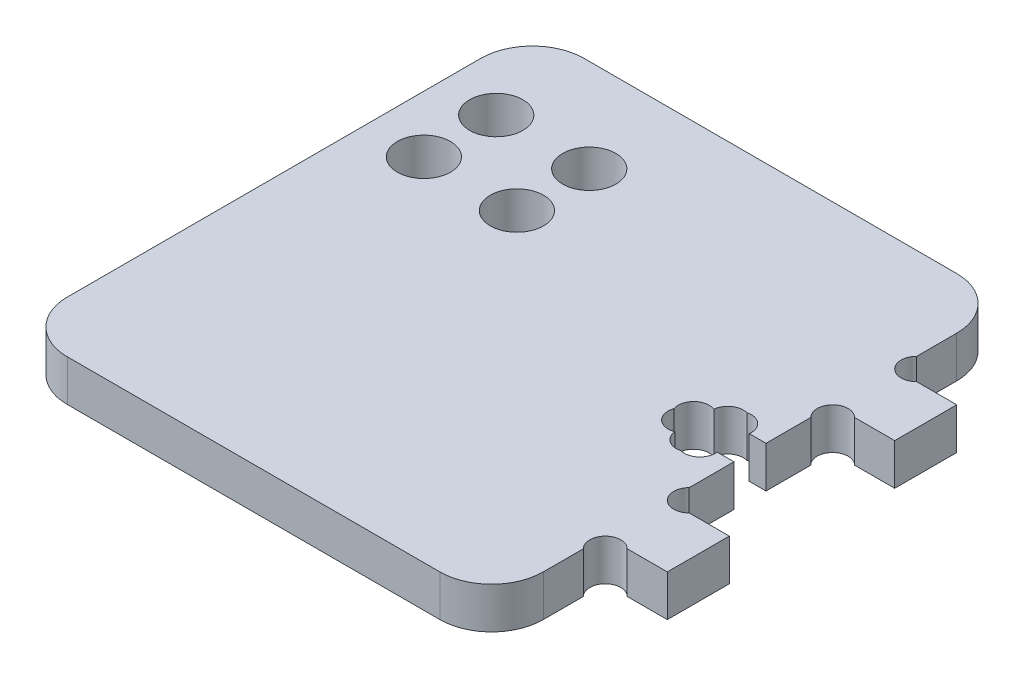
from build123d import *

# Parameters (mm, degrees)
SALIENTE_EXTRUIR1_DEPTH = 4
CORTAR_EXTRUIR4_DEPTH   = 5
CROQUIS10_R             = 1.5
CORTAR_EXTRUIR5_DEPTH   = 5
CROQUIS12_R             = 2.575
CORTAR_EXTRUIR6_DEPTH   = 5


with BuildPart() as part:
    # Croquis1 → Saliente-Extruir1 (new body)
    with BuildSketch(Plane(origin=(0, 0, 0), x_dir=(1, 0, 0), z_dir=(0, 1, 0))):
        with BuildLine():
            Line((-18.025, -25), (18.025, -25))
            ThreePointArc((18.025, -25), (21.560533906, -23.535533906), (23.025, -20))
            Line((23.025, -20), (23.025, -14))
            Line((23.025, -14), (29.025, -14))
            Line((29.025, -14), (29.025, -8))
            Line((29.025, -8), (23.025, -8))
            Line((23.025, -8), (23.025, -1.55))
            Line((23.025, -1.55), (20.975, -1.55))
            Line((20.975, -1.55), (20.975, -2.8))
            Line((20.975, -2.8), (18.075, -2.8))
            Line((18.075, -2.8), (18.075, -1.55))
            Line((18.075, -1.55), (16.025, -1.55))
            Line((16.025, -1.55), (16.025, 1.55))
            Line((16.025, 1.55), (18.075, 1.55))
            Line((18.075, 1.55), (18.075, 2.8))
            Line((18.075, 2.8), (20.975, 2.8))
            Line((20.975, 2.8), (20.975, 1.55))
            Line((20.975, 1.55), (23.025, 1.55))
            Line((23.025, 1.55), (23.025, 8))
            Line((23.025, 8), (29.025, 8))
            Line((29.025, 8), (29.025, 14))
            Line((29.025, 14), (23.025, 14))
            Line((23.025, 14), (23.025, 20))
            ThreePointArc((23.025, 20), (21.560533906, 23.535533906), (18.025, 25))
            Line((18.025, 25), (-18.025, 25))
            ThreePointArc((-18.025, 25), (-21.560533906, 23.535533906), (-23.025, 20))
            Line((-23.025, 20), (-23.025, -20))
            ThreePointArc((-23.025, -20), (-21.560533906, -23.535533906), (-18.025, -25))
        make_face()
    extrude(amount=SALIENTE_EXTRUIR1_DEPTH)

    # Croquis7 → Cortar-Extruir4 (cut, through all)
    with BuildSketch(Plane(origin=(0, 4, 0), x_dir=(1, 0, 0), z_dir=(0, 1, 0))):
        with BuildLine():
            Line((21.402341989, 1.55), (23.025, 1.55))
            Line((23.025, 1.55), (23.025, -1.55))
            Line((23.025, -1.55), (21.402341989, -1.55))
            ThreePointArc((21.402341989, -1.55), (20.900478098, -2.869619136), (19.525, -3.187930349))
            ThreePointArc((19.525, -3.187930349), (18.280747615, -2.971867524), (17.642475162, -1.882163243))
            ThreePointArc((17.642475162, -1.882163243), (16.05076038, -1.575149398), (15.66772275, 0))
            ThreePointArc((15.66772275, 0), (16.05076038, 1.575149398), (17.642475162, 1.882163243))
            ThreePointArc((17.642475162, 1.882163243), (18.280747615, 2.971867524), (19.525, 3.187930349))
            ThreePointArc((19.525, 3.187930349), (20.900478098, 2.869619136), (21.402341989, 1.55))
        make_face()
    extrude(amount=-CORTAR_EXTRUIR4_DEPTH, mode=Mode.SUBTRACT)

    # Croquis10 → Cortar-Extruir5 (cut, through all)
    with BuildSketch(Plane(origin=(0, 4, 0), x_dir=(1, 0, 0), z_dir=(0, 1, 0))):
        with Locations((24.085660172, 15.060660172)):
            Circle(CROQUIS10_R)
        with Locations((24.085660172, 6.939339828)):
            Circle(CROQUIS10_R)
        with Locations((24.085660172, -15.060660172)):
            Circle(CROQUIS10_R)
        with Locations((24.085660172, -6.939339828)):
            Circle(CROQUIS10_R)
    extrude(amount=-CORTAR_EXTRUIR5_DEPTH, mode=Mode.SUBTRACT)

    # Croquis12 → Cortar-Extruir6 (cut, through all)
    with BuildSketch(Plane(origin=(0, 4, 0), x_dir=(1, 0, 0), z_dir=(0, 1, 0))):
        with Locations((-17.525, 16)):
            Circle(CROQUIS12_R)
        with Locations((-8.525, 16)):
            Circle(CROQUIS12_R)
        with Locations((-8.525, 9)):
            Circle(CROQUIS12_R)
        with Locations((-17.525, 9)):
            Circle(CROQUIS12_R)
    extrude(amount=-CORTAR_EXTRUIR6_DEPTH, mode=Mode.SUBTRACT)


solid = part.part
